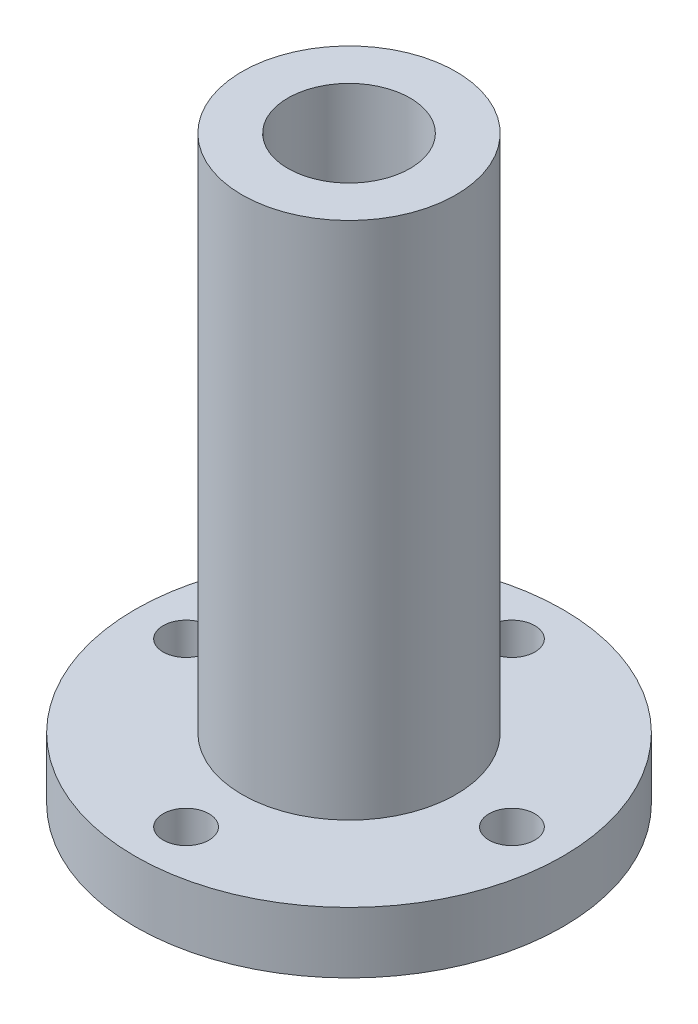
from build123d import *

# Parameters (mm, degrees)
SKETCH1_R           = 21
SKETCH1_R_2         = 6
BOSS_EXTRUDE1_DEPTH = 6
SKETCH2_R           = 10.5
SKETCH2_R_2         = 6
BOSS_EXTRUDE2_DEPTH = 51
CUT_EXTRUDE1_REACH  = 59
SKETCH3_R           = 2.25


with BuildPart() as part:
    # Sketch1 → Boss-Extrude1 (new body)
    with BuildSketch(Plane(origin=(0, 0, 0), x_dir=(1, 0, 0), z_dir=(0, 1, 0))):
        Circle(SKETCH1_R)
        Circle(SKETCH1_R_2, mode=Mode.SUBTRACT)
    extrude(amount=BOSS_EXTRUDE1_DEPTH)

    # Sketch2 → Boss-Extrude2 (add)
    with BuildSketch(Plane(origin=(0, 6, 0), x_dir=(1, 0, 0), z_dir=(0, 1, 0))):
        Circle(SKETCH2_R)
        Circle(SKETCH2_R_2, mode=Mode.SUBTRACT)
    extrude(amount=BOSS_EXTRUDE2_DEPTH)

    # Sketch3 → Cut-Extrude1 (cut, up to next)
    with BuildSketch(Plane.XZ, mode=Mode.PRIVATE) as cut_extrude1_sk1:
        with Locations((0, 16)):
            Circle(SKETCH3_R)
    cut_extrude1_tool1 = extrude(cut_extrude1_sk1.sketch, amount=-CUT_EXTRUDE1_REACH, mode=Mode.PRIVATE) & part.part
    add(cut_extrude1_tool1.solids().sort_by_distance((0, 0, 16))[0], mode=Mode.SUBTRACT)
    # Sketch3 → Cut-Extrude1 (cut, up to next)
    with BuildSketch(Plane.XZ, mode=Mode.PRIVATE) as cut_extrude1_sk2:
        with Locations((16, 0)):
            Circle(SKETCH3_R)
    cut_extrude1_tool2 = extrude(cut_extrude1_sk2.sketch, amount=-CUT_EXTRUDE1_REACH, mode=Mode.PRIVATE) & part.part
    add(cut_extrude1_tool2.solids().sort_by_distance((16, 0, 0))[0], mode=Mode.SUBTRACT)
    # Sketch3 → Cut-Extrude1 (cut, up to next)
    with BuildSketch(Plane.XZ, mode=Mode.PRIVATE) as cut_extrude1_sk3:
        with Locations((0, -16)):
            Circle(SKETCH3_R)
    cut_extrude1_tool3 = extrude(cut_extrude1_sk3.sketch, amount=-CUT_EXTRUDE1_REACH, mode=Mode.PRIVATE) & part.part
    add(cut_extrude1_tool3.solids().sort_by_distance((0, 0, -16))[0], mode=Mode.SUBTRACT)
    # Sketch3 → Cut-Extrude1 (cut, up to next)
    with BuildSketch(Plane.XZ, mode=Mode.PRIVATE) as cut_extrude1_sk4:
        with Locations((-16, 0)):
            Circle(SKETCH3_R)
    cut_extrude1_tool4 = extrude(cut_extrude1_sk4.sketch, amount=-CUT_EXTRUDE1_REACH, mode=Mode.PRIVATE) & part.part
    add(cut_extrude1_tool4.solids().sort_by_distance((-16, 0, 0))[0], mode=Mode.SUBTRACT)


solid = part.part
